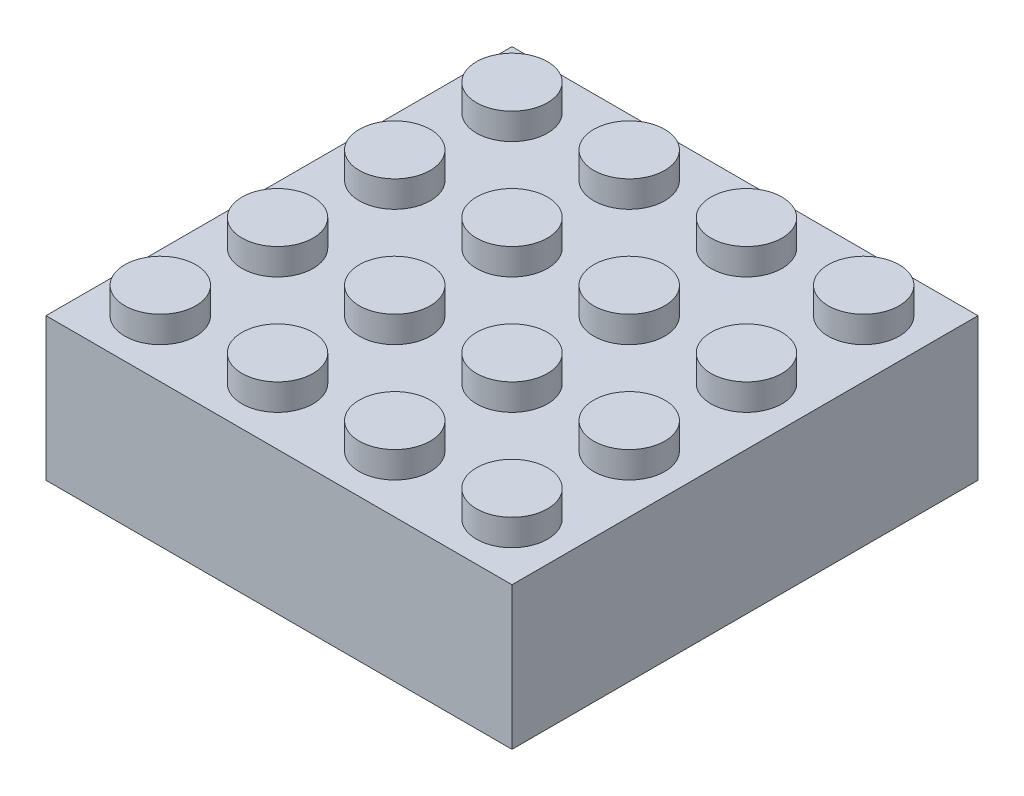
from build123d import *

# Parameters (mm, degrees)
SKETCH2_R              = 2.425
BOSS_EXTRUDE1_DEPTH    = 1.8
BOSS_EXTRUDE1_2_DEPTH  = 1.8
BOSS_EXTRUDE1_3_DEPTH  = 1.8
BOSS_EXTRUDE1_4_DEPTH  = 1.8
BOSS_EXTRUDE1_5_DEPTH  = 1.8
BOSS_EXTRUDE1_6_DEPTH  = 1.8
BOSS_EXTRUDE1_7_DEPTH  = 1.8
BOSS_EXTRUDE1_8_DEPTH  = 1.8
BOSS_EXTRUDE1_9_DEPTH  = 1.8
BOSS_EXTRUDE1_10_DEPTH = 1.8
BOSS_EXTRUDE1_11_DEPTH = 1.8
BOSS_EXTRUDE1_12_DEPTH = 1.8
BOSS_EXTRUDE1_13_DEPTH = 1.8
BOSS_EXTRUDE1_14_DEPTH = 1.8
BOSS_EXTRUDE1_15_DEPTH = 1.8
BOSS_EXTRUDE1_16_DEPTH = 1.8
SKETCH1_W              = 31.8
SKETCH1_H              = 31.8
BOSS_EXTRUDE2_DEPTH    = 9.73
CUT_EXTRUDE1_DEPTH     = 6.63
SKETCH9_W              = 8.211044263
SKETCH9_H              = 1.75
BOSS_EXTRUDE4_DEPTH    = 1.5
BOSS_EXTRUDE5_DEPTH    = 8.211044
CUT_EXTRUDE4_DEPTH     = 8.211044
CIRPATTERN3_COUNT      = 6


with BuildPart() as part:
    # Sketch2 → Boss-Extrude1 (new body)
    with BuildSketch(Plane(origin=(0, 0, 0), x_dir=(1, 0, 0), z_dir=(0, 1, 0))):
        with Locations((3.9, 27.9)):
            Circle(SKETCH2_R)
    extrude(amount=BOSS_EXTRUDE1_DEPTH)

    # Sketch1 → Boss-Extrude2 (add)
    with BuildSketch(Plane(origin=(0, 0, 0), x_dir=(1, 0, 0), z_dir=(0, 1, 0))):
        with Locations((15.9, 15.9)):
            Rectangle(SKETCH1_W, SKETCH1_H)
    extrude(amount=-BOSS_EXTRUDE2_DEPTH)

    # Sketch4 → Cut-Extrude1 (cut)
    with BuildSketch(Plane.XZ.offset(9.73)):
        Polygon((26.085733965, -15.874437919), (21.016403127, -7.092489065), (10.805424678, -7.07984512), (5.714275589, -15.929121347), (10.830590574, -24.734643054), (21.015442313, -24.708069014), align=None)
    extrude(amount=-CUT_EXTRUDE1_DEPTH, mode=Mode.SUBTRACT)

    # Sketch9 → Boss-Extrude4 (add)
    with BuildSketch(Plane.XZ.offset(9.73)):
        with Locations((15.910946043, -6.206083389)):
            Rectangle(SKETCH9_W, SKETCH9_H)
    boss_extrude4 = extrude(amount=BOSS_EXTRUDE4_DEPTH)

    # Sketch10 → Boss-Extrude5 (add)
    with BuildSketch(Plane(origin=(20.016468174, 0, 0), x_dir=(0, 0, -1), z_dir=(1, 0, 0))):
        Polygon((7.081083389, -11.23), (7.981083389, -9.83), (7.081083389, -9.73), align=None)
    boss_extrude5 = extrude(amount=-BOSS_EXTRUDE5_DEPTH)

    # Sketch11 → Cut-Extrude4 (cut)
    with BuildSketch(Plane(origin=(20.016468174, 0, 0), x_dir=(0, 0, -1), z_dir=(1, 0, 0))):
        Polygon((6.331083389, -11.23), (5.331083389, -9.73), (5.331083389, -11.23), align=None)
    cut_extrude4 = extrude(amount=-CUT_EXTRUDE4_DEPTH, mode=Mode.SUBTRACT)

    # CirPattern3: Boss-Extrude4, Boss-Extrude5, Cut-Extrude4 ×6 about axis
    cirpattern3_axis = Axis((15.9, 0, -15.9), (0, 1, 0))
    for i in range(1, CIRPATTERN3_COUNT):
        add(boss_extrude4.rotate(cirpattern3_axis, i * 360 / CIRPATTERN3_COUNT))
        add(boss_extrude5.rotate(cirpattern3_axis, i * 360 / CIRPATTERN3_COUNT))
        add(cut_extrude4.rotate(cirpattern3_axis, i * 360 / CIRPATTERN3_COUNT), mode=Mode.SUBTRACT)


with BuildPart() as body_2:
    # Sketch2 → Boss-Extrude1 2 (new body)
    with BuildSketch(Plane(origin=(0, 0, 0), x_dir=(1, 0, 0), z_dir=(0, 1, 0))):
        with Locations((11.9, 27.9)):
            Circle(SKETCH2_R)
    extrude(amount=BOSS_EXTRUDE1_2_DEPTH)


with BuildPart() as body_3:
    # Sketch2 → Boss-Extrude1 3 (new body)
    with BuildSketch(Plane(origin=(0, 0, 0), x_dir=(1, 0, 0), z_dir=(0, 1, 0))):
        with Locations((19.9, 27.9)):
            Circle(SKETCH2_R)
    extrude(amount=BOSS_EXTRUDE1_3_DEPTH)


with BuildPart() as body_4:
    # Sketch2 → Boss-Extrude1 4 (new body)
    with BuildSketch(Plane(origin=(0, 0, 0), x_dir=(1, 0, 0), z_dir=(0, 1, 0))):
        with Locations((27.9, 27.9)):
            Circle(SKETCH2_R)
    extrude(amount=BOSS_EXTRUDE1_4_DEPTH)


with BuildPart() as body_5:
    # Sketch2 → Boss-Extrude1 5 (new body)
    with BuildSketch(Plane(origin=(0, 0, 0), x_dir=(1, 0, 0), z_dir=(0, 1, 0))):
        with Locations((11.9, 19.9)):
            Circle(SKETCH2_R)
    extrude(amount=BOSS_EXTRUDE1_5_DEPTH)


with BuildPart() as body_6:
    # Sketch2 → Boss-Extrude1 6 (new body)
    with BuildSketch(Plane(origin=(0, 0, 0), x_dir=(1, 0, 0), z_dir=(0, 1, 0))):
        with Locations((19.9, 19.9)):
            Circle(SKETCH2_R)
    extrude(amount=BOSS_EXTRUDE1_6_DEPTH)


with BuildPart() as body_7:
    # Sketch2 → Boss-Extrude1 7 (new body)
    with BuildSketch(Plane(origin=(0, 0, 0), x_dir=(1, 0, 0), z_dir=(0, 1, 0))):
        with Locations((27.9, 19.9)):
            Circle(SKETCH2_R)
    extrude(amount=BOSS_EXTRUDE1_7_DEPTH)


with BuildPart() as body_8:
    # Sketch2 → Boss-Extrude1 8 (new body)
    with BuildSketch(Plane(origin=(0, 0, 0), x_dir=(1, 0, 0), z_dir=(0, 1, 0))):
        with Locations((11.9, 11.9)):
            Circle(SKETCH2_R)
    extrude(amount=BOSS_EXTRUDE1_8_DEPTH)


with BuildPart() as body_9:
    # Sketch2 → Boss-Extrude1 9 (new body)
    with BuildSketch(Plane(origin=(0, 0, 0), x_dir=(1, 0, 0), z_dir=(0, 1, 0))):
        with Locations((19.9, 11.9)):
            Circle(SKETCH2_R)
    extrude(amount=BOSS_EXTRUDE1_9_DEPTH)


with BuildPart() as body_10:
    # Sketch2 → Boss-Extrude1 10 (new body)
    with BuildSketch(Plane(origin=(0, 0, 0), x_dir=(1, 0, 0), z_dir=(0, 1, 0))):
        with Locations((27.9, 11.9)):
            Circle(SKETCH2_R)
    extrude(amount=BOSS_EXTRUDE1_10_DEPTH)


with BuildPart() as body_11:
    # Sketch2 → Boss-Extrude1 11 (new body)
    with BuildSketch(Plane(origin=(0, 0, 0), x_dir=(1, 0, 0), z_dir=(0, 1, 0))):
        with Locations((11.9, 3.9)):
            Circle(SKETCH2_R)
    extrude(amount=BOSS_EXTRUDE1_11_DEPTH)


with BuildPart() as body_12:
    # Sketch2 → Boss-Extrude1 12 (new body)
    with BuildSketch(Plane(origin=(0, 0, 0), x_dir=(1, 0, 0), z_dir=(0, 1, 0))):
        with Locations((19.9, 3.9)):
            Circle(SKETCH2_R)
    extrude(amount=BOSS_EXTRUDE1_12_DEPTH)


with BuildPart() as body_13:
    # Sketch2 → Boss-Extrude1 13 (new body)
    with BuildSketch(Plane(origin=(0, 0, 0), x_dir=(1, 0, 0), z_dir=(0, 1, 0))):
        with Locations((27.9, 3.9)):
            Circle(SKETCH2_R)
    extrude(amount=BOSS_EXTRUDE1_13_DEPTH)


with BuildPart() as body_14:
    # Sketch2 → Boss-Extrude1 14 (new body)
    with BuildSketch(Plane(origin=(0, 0, 0), x_dir=(1, 0, 0), z_dir=(0, 1, 0))):
        with Locations((3.9, 19.9)):
            Circle(SKETCH2_R)
    extrude(amount=BOSS_EXTRUDE1_14_DEPTH)


with BuildPart() as body_15:
    # Sketch2 → Boss-Extrude1 15 (new body)
    with BuildSketch(Plane(origin=(0, 0, 0), x_dir=(1, 0, 0), z_dir=(0, 1, 0))):
        with Locations((3.9, 11.9)):
            Circle(SKETCH2_R)
    extrude(amount=BOSS_EXTRUDE1_15_DEPTH)


with BuildPart() as body_16:
    # Sketch2 → Boss-Extrude1 16 (new body)
    with BuildSketch(Plane(origin=(0, 0, 0), x_dir=(1, 0, 0), z_dir=(0, 1, 0))):
        with Locations((3.9, 3.9)):
            Circle(SKETCH2_R)
    extrude(amount=BOSS_EXTRUDE1_16_DEPTH)


solid = Compound([part.part, body_2.part, body_3.part, body_4.part, body_5.part, body_6.part, body_7.part, body_8.part, body_9.part, body_10.part, body_11.part, body_12.part, body_13.part, body_14.part, body_15.part, body_16.part])
